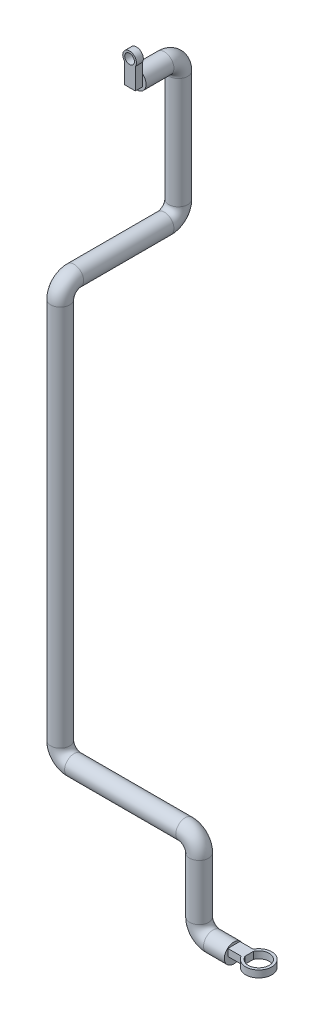
from build123d import *

# Parameters (mm, degrees)
CROQUIS1_R              = 13.7
CROQUIS2_R              = 18.802363286
CROQUIS2_R_2            = 15
SALIENTE_EXTRUIR1_DEPTH = 10
CROQUIS3_W              = 44.13588892
CROQUIS3_H              = 17.311093538
SALIENTE_EXTRUIR2_DEPTH = 10
CROQUIS4_R              = 9.856614663
CROQUIS4_R_2            = 7
SALIENTE_EXTRUIR3_DEPTH = 10
SALIENTE_EXTRUIR4_DEPTH = 10
SALIENTE_EXTRUIR5_DEPTH = 10


with BuildPart() as part:
    # Barrer1: sweep along a curve in space
    with BuildLine() as barrer1_path:
        Line((0, 0, 0), (-30, 0, 0))
        ThreePointArc((-30, 0, 0), (-44.142135624, 5.857864376, 0), (-50, 20, 0))
        Line((-50, 20, 0), (-50, 100, 0))
        ThreePointArc((-70, 120, 0), (-55.857864376, 114.142135624, 0), (-50, 100, 0))
        Line((-70, 120, 0), (-230, 120, 0))
        ThreePointArc((-230, 120, 0), (-244.142135624, 125.857864376, 0), (-250, 140, 0))
        Line((-250, 140, 0), (-250, 690, 0))
        ThreePointArc((-250, 690, 0), (-250, 704.142135624, -5.857864376), (-250, 710, -20))
        Line((-250, 710, -20), (-250, 710, -150))
        ThreePointArc((-250, 710, -150), (-250, 715.857864376, -164.142135624), (-250, 730, -170))
        Line((-250, 730, -170), (-250, 890, -170))
        ThreePointArc((-250, 890, -170), (-250, 904.142135624, -164.142135624), (-250, 910, -150))
        Line((-250, 910, -150), (-250, 910, -109.84735752))
    # Croquis1 → Barrer1 (sweep)
    with BuildSketch(Plane(origin=(0, 0, 0), x_dir=(0, 0, -1), z_dir=(1, 0, 0))):
        Circle(CROQUIS1_R)
    sweep(path=barrer1_path.line)



with BuildPart() as body_2:
    # Croquis2 → Saliente-Extruir1 (new body)
    with BuildSketch(Plane(origin=(0, 0, 0), x_dir=(1, 0, 0), z_dir=(0, 1, 0))):
        with Locations((35.829122369, 0)):
            Circle(CROQUIS2_R)
        with Locations((35.829122369, 0)):
            Circle(CROQUIS2_R_2, mode=Mode.SUBTRACT)
    extrude(amount=SALIENTE_EXTRUIR1_DEPTH)


with BuildPart() as part_1:
    add(part.part)

    add(body_2.part)  # Saliente-Extruir2 merges body 2
    # Croquis3 → Saliente-Extruir2 (add)
    with BuildSketch(Plane(origin=(0, 0, 0), x_dir=(1, 0, 0), z_dir=(0, 1, 0))):
        Rectangle(CROQUIS3_W, CROQUIS3_H)
    extrude(amount=SALIENTE_EXTRUIR2_DEPTH)



with BuildPart() as body_2_2:
    # Croquis4 → Saliente-Extruir3 (new body)
    with BuildSketch(Plane.XY.offset(-109.84735752)):
        with Locations((-250, 940)):
            Circle(CROQUIS4_R)
        with Locations((-250, 940)):
            Circle(CROQUIS4_R_2, mode=Mode.SUBTRACT)
    extrude(amount=SALIENTE_EXTRUIR3_DEPTH)

    # Croquis5 → Saliente-Extruir4 (add)
    with BuildSketch(Plane.XY.offset(-109.84735752)):
        with BuildLine():
            Line((-241.746737266, 934.611446683), (-245.5319475, 934.611446683))
            ThreePointArc((-245.5319475, 934.611446683), (-250, 933), (-254.4680525, 934.611446683))
            Line((-254.4680525, 934.611446683), (-256.956251406, 934.611446683))
            Line((-256.956251406, 934.611446683), (-256.956251406, 921.802566093))
            ThreePointArc((-256.956251406, 921.802566093), (-249.219782948, 923.677765218), (-241.746737266, 920.934973902))
            Line((-241.746737266, 920.934973902), (-241.746737266, 934.611446683))
        make_face()
    extrude(amount=SALIENTE_EXTRUIR4_DEPTH)


with BuildPart() as part_2:
    add(part_1.part)

    add(body_2_2.part)  # Saliente-Extruir5 merges body 2 2
    # Croquis6 → Saliente-Extruir5 (add)
    with BuildSketch(Plane.XY.offset(-99.84735752)):
        with BuildLine():
            Line((-256.956251406, 921.802566093), (-256.956251406, 904.048678117))
            Line((-256.956251406, 904.048678117), (-241.746737266, 904.048678117))
            Line((-241.746737266, 904.048678117), (-241.746737266, 920.934973902))
            ThreePointArc((-241.746737266, 920.934973902), (-249.219782948, 923.677765218), (-256.956251406, 921.802566093))
        make_face()
    extrude(amount=-SALIENTE_EXTRUIR5_DEPTH)


solid = part_2.part
